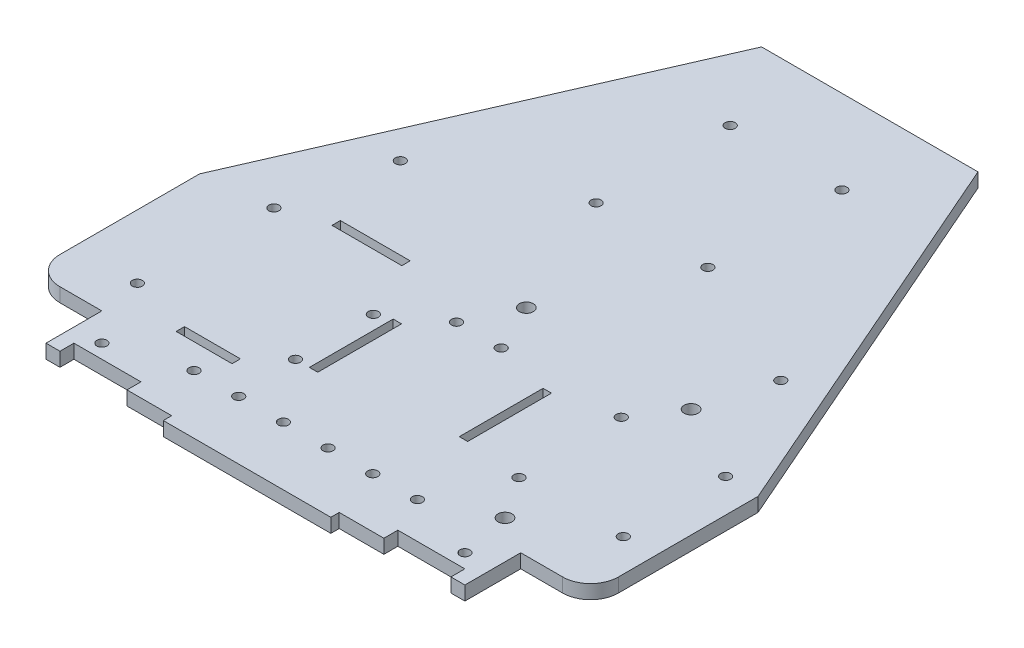
from build123d import *

# Parameters (mm, degrees)
BOSS_EXTRUDE1_DEPTH = 5
SKETCH3_R           = 1.8
SKETCH3_W           = 20
SKETCH3_H           = 3
SKETCH3_W_2         = 25
SKETCH3_W_3         = 3
SKETCH3_H_2         = 30
ARDUINO_DEPTH       = 6
SKETCH6_R           = 1.8
CUT_EXTRUDE4_DEPTH  = 6
SKETCH8_R           = 1.8
CUT_EXTRUDE5_DEPTH  = 10
SKETCH9_R           = 1.8
SKETCH9_R_2         = 2.5
SKETCH9_W           = 3
SKETCH9_H           = 30
L298N_DEPTH         = 10
SKETCH11_W          = 24
SKETCH11_H          = 5
CUT_EXTRUDE7_DEPTH  = 10
SKETCH12_W          = 100
SKETCH12_H          = 20
CUT_EXTRUDE8_DEPTH  = 10


with BuildPart() as part:
    # Sketch1 → Boss-Extrude1 (new body)
    with BuildSketch(Plane(origin=(0, 0, 0), x_dir=(1, 0, 0), z_dir=(0, 1, 0))):
        with BuildLine():
            Line((100, -40), (100, 10))
            Line((100, 10), (30, 170))
            Line((30, 170), (-30, 170))
            Line((-30, 170), (-100, 10))
            Line((-100, 10), (-100, -40))
            ThreePointArc((-100, -40), (-97.071067812, -47.071067812), (-90, -50))
            Line((-90, -50), (-75, -50))
            Line((-75, -50), (-75, -70))
            Line((-75, -70), (-30, -70))
            Line((-30, -70), (-30, -73))
            Line((-30, -73), (30, -73))
            Line((30, -73), (30, -70))
            Line((30, -70), (75, -70))
            Line((75, -70), (75, -50))
            Line((75, -50), (90, -50))
            ThreePointArc((90, -50), (97.071067812, -47.071067812), (100, -40))
        make_face()
    extrude(amount=BOSS_EXTRUDE1_DEPTH)

    # Sketch3 → arduino (cut, through all)
    with BuildSketch(Plane(origin=(0, 5, 0), x_dir=(1, 0, 0), z_dir=(0, 1, 0))):
        with Locations((-76.120983048, 12.737637313)):
            Circle(SKETCH3_R)
        with Locations((-77.220983048, -35.062362687)):
            Circle(SKETCH3_R)
        with Locations((-25.320983048, -2.462362687)):
            Circle(SKETCH3_R)
        with Locations((-25.320983048, -30.362362687)):
            Circle(SKETCH3_R)
        with Locations((-45.320983048, -41.562362687)):
            Rectangle(SKETCH3_W, SKETCH3_H)
        with Locations((-47.820983048, 19.237637313)):
            Rectangle(SKETCH3_W_2, SKETCH3_H)
        with Locations((-18.820983048, -15.362362687)):
            Rectangle(SKETCH3_W_3, SKETCH3_H_2)
    extrude(amount=-ARDUINO_DEPTH, mode=Mode.SUBTRACT)

    # Sketch6 → Cut-Extrude4 (cut, through all)
    with BuildSketch(Plane(origin=(0, 5, 0), x_dir=(1, 0, 0), z_dir=(0, 1, 0))):
        with Locations((20, 120)):
            Circle(SKETCH6_R)
        with Locations((-20, 120)):
            Circle(SKETCH6_R)
    extrude(amount=-CUT_EXTRUDE4_DEPTH, mode=Mode.SUBTRACT)

    # Sketch8 → Cut-Extrude5 (cut)
    with BuildSketch(Plane(origin=(0, 5, 0), x_dir=(1, 0, 0), z_dir=(0, 1, 0))):
        with Locations((8, 10)):
            Circle(SKETCH8_R)
        with Locations((-8, 10)):
            Circle(SKETCH8_R)
        with Locations((-65, -60)):
            Circle(SKETCH8_R)
        with Locations((65, -60)):
            Circle(SKETCH8_R)
        with Locations((8, -52)):
            Circle(SKETCH8_R)
        with Locations((24, -52)):
            Circle(SKETCH8_R)
        with Locations((40, -52)):
            Circle(SKETCH8_R)
        with Locations((-8, -52)):
            Circle(SKETCH8_R)
        with Locations((-40, -52)):
            Circle(SKETCH8_R)
        with Locations((-24, -52)):
            Circle(SKETCH8_R)
    extrude(amount=-CUT_EXTRUDE5_DEPTH, mode=Mode.SUBTRACT)

    # Sketch9 → l298n (cut)
    with BuildSketch(Plane(origin=(0, 5, 0), x_dir=(1, 0, 0), z_dir=(0, 1, 0))):
        with Locations((20, 72)):
            Circle(SKETCH9_R)
        with Locations((-20, 72)):
            Circle(SKETCH9_R)
        with Locations((51, 10)):
            Circle(SKETCH9_R)
        with Locations((87.998174007, 10.367586933)):
            Circle(SKETCH9_R)
        with Locations((88.36576094, -26.630587074)):
            Circle(SKETCH9_R)
        with Locations((51.367586933, -26.998174007)):
            Circle(SKETCH9_R)
        with Locations((-68.125, 50)):
            Circle(SKETCH9_R)
        with Locations((68.125, 50)):
            Circle(SKETCH9_R)
        with Locations((61, 25)):
            Circle(SKETCH9_R_2)
        with Locations((61.367586933, -41.998174007)):
            Circle(SKETCH9_R_2)
        with Locations((0, 27)):
            Circle(SKETCH9_R_2)
        with Locations((29.5, -10)):
            Rectangle(SKETCH9_W, SKETCH9_H)
    extrude(amount=-L298N_DEPTH, mode=Mode.SUBTRACT)

    # Sketch11 → Cut-Extrude7 (cut)
    with BuildSketch(Plane(origin=(0, 5, 0), x_dir=(1, 0, 0), z_dir=(0, 1, 0))):
        with Locations((-58, -67.5)):
            Rectangle(SKETCH11_W, SKETCH11_H)
        with Locations((58, -67.5)):
            Rectangle(SKETCH11_W, SKETCH11_H)
    extrude(amount=-CUT_EXTRUDE7_DEPTH, mode=Mode.SUBTRACT)

    # Sketch12 → Cut-Extrude8 (cut)
    with BuildSketch(Plane(origin=(0, 5, 0), x_dir=(1, 0, 0), z_dir=(0, 1, 0))):
        with Locations((0, 160)):
            Rectangle(SKETCH12_W, SKETCH12_H)
    extrude(amount=-CUT_EXTRUDE8_DEPTH, mode=Mode.SUBTRACT)


solid = part.part
